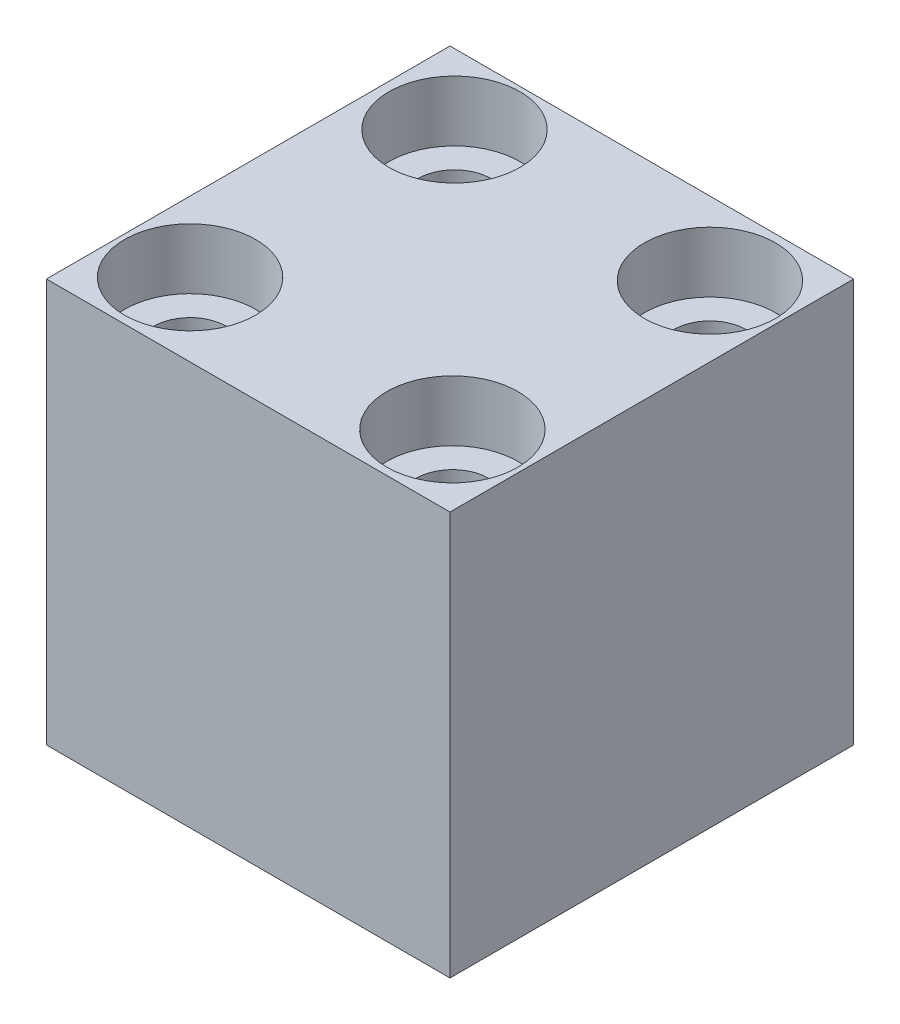
from build123d import *

# Parameters (mm, degrees)
ESBO_O1_W                         = 20
ESBO_O1_H                         = 20
RESSALTO_EXTRUS_O1_DEPTH          = 20
REBAIXO_PARA_SHCS_M32_D           = 3.6
REBAIXO_PARA_SHCS_M32_CBORE_D     = 6.5
REBAIXO_PARA_SHCS_M32_CBORE_DEPTH = 3


with BuildPart() as part:
    # Esboço1 → Ressalto-extrusão1 (new body)
    with BuildSketch(Plane(origin=(0, 0, 0), x_dir=(1, 0, 0), z_dir=(0, 1, 0))):
        Rectangle(ESBO_O1_W, ESBO_O1_H)
    extrude(amount=RESSALTO_EXTRUS_O1_DEPTH)

    # Rebaixo para SHCS M32 (through all)
    with Locations(Plane(origin=(-6.303242204, 20, -6.525555725), x_dir=(0, 0, 1), z_dir=(0, 1, 0))):
        with Locations((0, 0), (0.156927192, 12.815720663), (12.92033879, 12.815720663), (12.894184258, -0.209236255)):
            CounterBoreHole(REBAIXO_PARA_SHCS_M32_D / 2, REBAIXO_PARA_SHCS_M32_CBORE_D / 2, REBAIXO_PARA_SHCS_M32_CBORE_DEPTH)


solid = part.part
